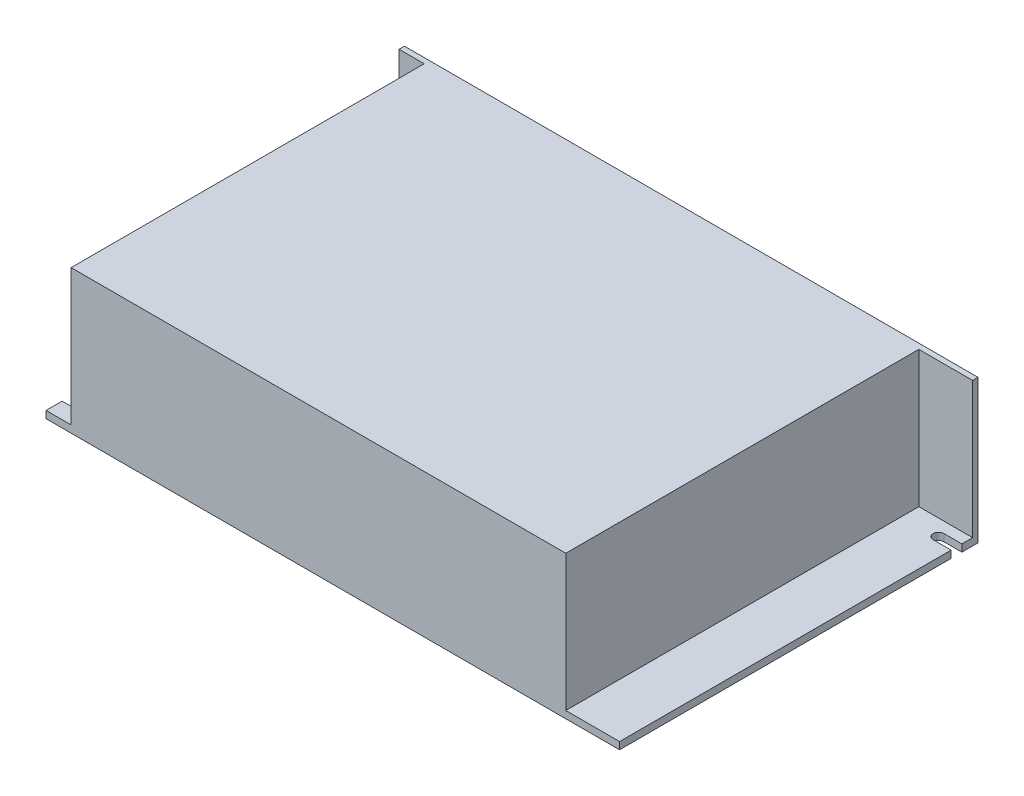
from build123d import *

# Parameters (mm, degrees)
SKETCH1_W           = 160
SKETCH1_H           = 40
BOSS_EXTRUDE1_DEPTH = 100
SKETCH2_W           = 7
SKETCH2_H           = 98.5
SKETCH2_W_2         = 15
CUT_EXTRUDE1_DEPTH  = 38
CUT_EXTRUDE2_DEPTH  = 2


with BuildPart() as part:
    # Sketch1 → Boss-Extrude1 (new body)
    with BuildSketch(Plane.XY):
        Rectangle(SKETCH1_W, SKETCH1_H)
    extrude(amount=BOSS_EXTRUDE1_DEPTH)

    # Sketch2 → Cut-Extrude1 (cut)
    with BuildSketch(Plane(origin=(0, 20, 0), x_dir=(1, 0, 0), z_dir=(0, 1, 0))):
        with Locations((-76.5, -50.75)):
            Rectangle(SKETCH2_W, SKETCH2_H)
        with Locations((72.5, -50.75)):
            Rectangle(SKETCH2_W_2, SKETCH2_H)
    extrude(amount=-CUT_EXTRUDE1_DEPTH, mode=Mode.SUBTRACT)

    # Sketch3 → Cut-Extrude2 (cut)
    with BuildSketch(Plane(origin=(0, -18, 0), x_dir=(1, 0, 0), z_dir=(0, 1, 0))):
        with BuildLine():
            Line((80, -4.5), (75, -4.5))
            ThreePointArc((75, -4.5), (73.5, -6), (75, -7.5))
            Line((75, -7.5), (80, -7.5))
            Line((80, -7.5), (80, -4.5))
        make_face()
        with BuildLine():
            Line((-80, -92.5), (-75, -92.5))
            ThreePointArc((-75, -92.5), (-73.5, -94), (-75, -95.5))
            Line((-75, -95.5), (-80, -95.5))
            Line((-80, -95.5), (-80, -92.5))
        make_face()
    extrude(amount=-CUT_EXTRUDE2_DEPTH, mode=Mode.SUBTRACT)


solid = part.part
